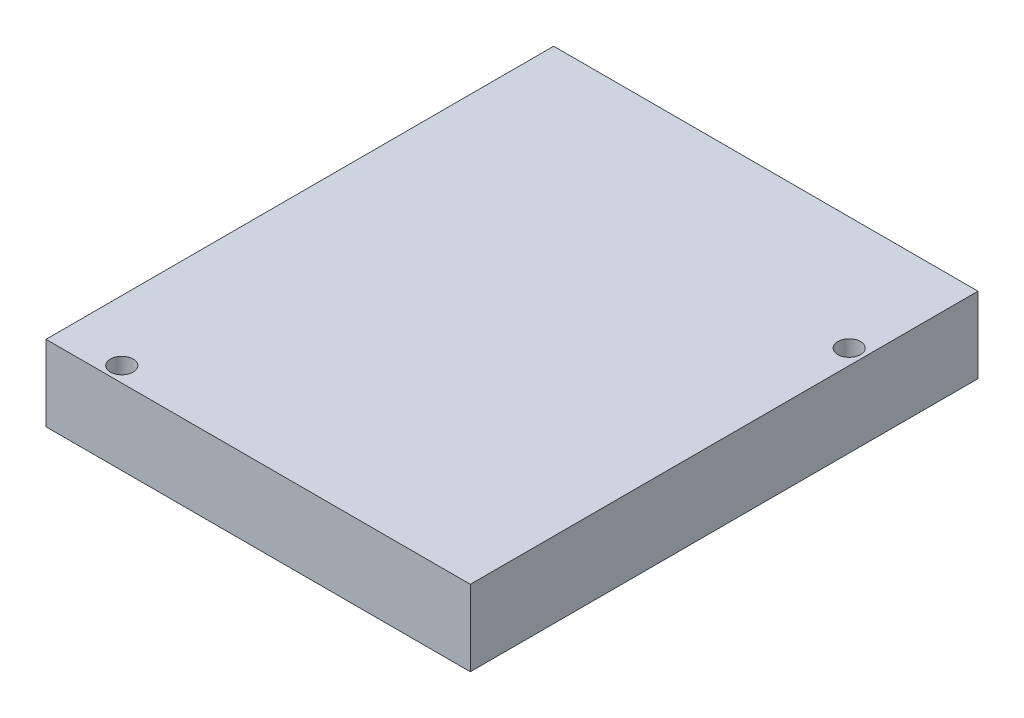
from build123d import *

# Parameters (mm, degrees)
SKETCH_1_W      = 56
SKETCH_1_H      = 67
SKETCH_1_R      = 1.5
EXTRUDE_1_DEPTH = 10


with BuildPart() as part:
    # Эскиз1 → Бобышка-Вытянуть1 (new body)
    with BuildSketch(Plane(origin=(0, 0, 0), x_dir=(1, 0, 0), z_dir=(0, 1, 0))):
        Rectangle(SKETCH_1_W, SKETCH_1_H)
        with Locations((26, 18.5)):
            Circle(SKETCH_1_R, mode=Mode.SUBTRACT)
        with Locations((-20, -31.5)):
            Circle(SKETCH_1_R, mode=Mode.SUBTRACT)
    extrude(amount=EXTRUDE_1_DEPTH)


solid = part.part
